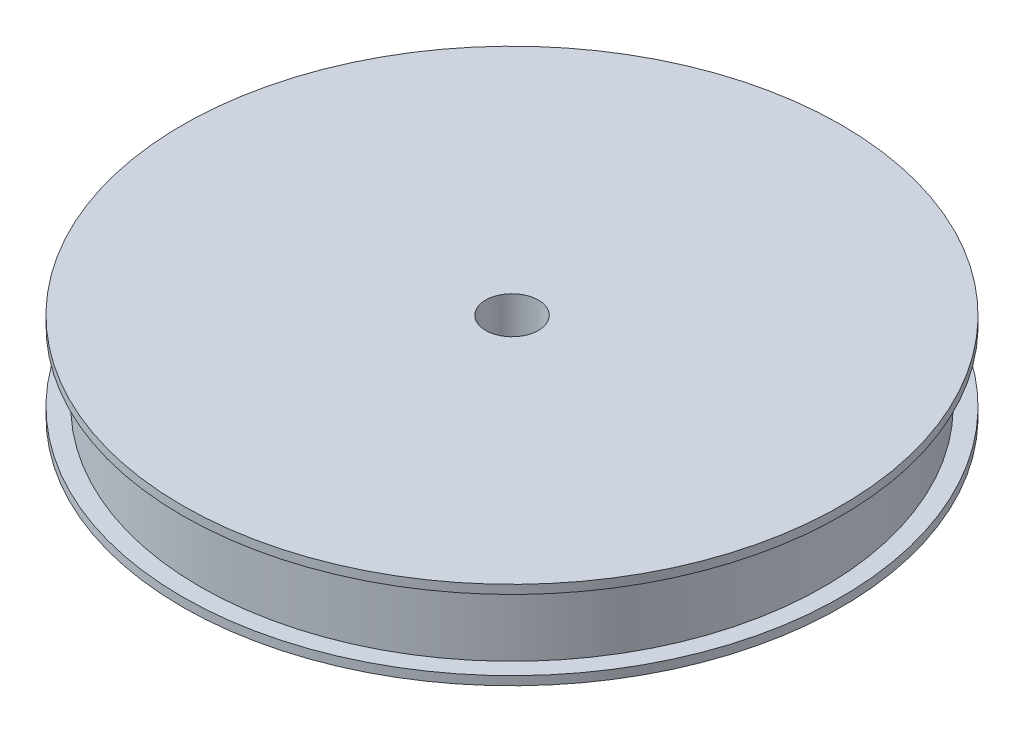
from build123d import *


with BuildPart() as part:
    # Sketch1 → Revolve1 (revolve)
    with BuildSketch(Plane.XY):
        Polygon((-13.146540644, 2.5), (-18.75, 2.5), (-18.75, 2), (-17.75, 2), (-17.75, 0), (-1.5, 0), (-1.5, 2.5), align=None)
    revolve1 = revolve(axis=Axis((0, 14.394370017, 0), (0, -1, 0)))

    # Mirror1: Revolve1 across Top Plane
    add(revolve1.mirror(Plane(origin=(0, 0, 0), x_dir=(1, 0, 0), z_dir=(0, 1, 0))))


solid = part.part
